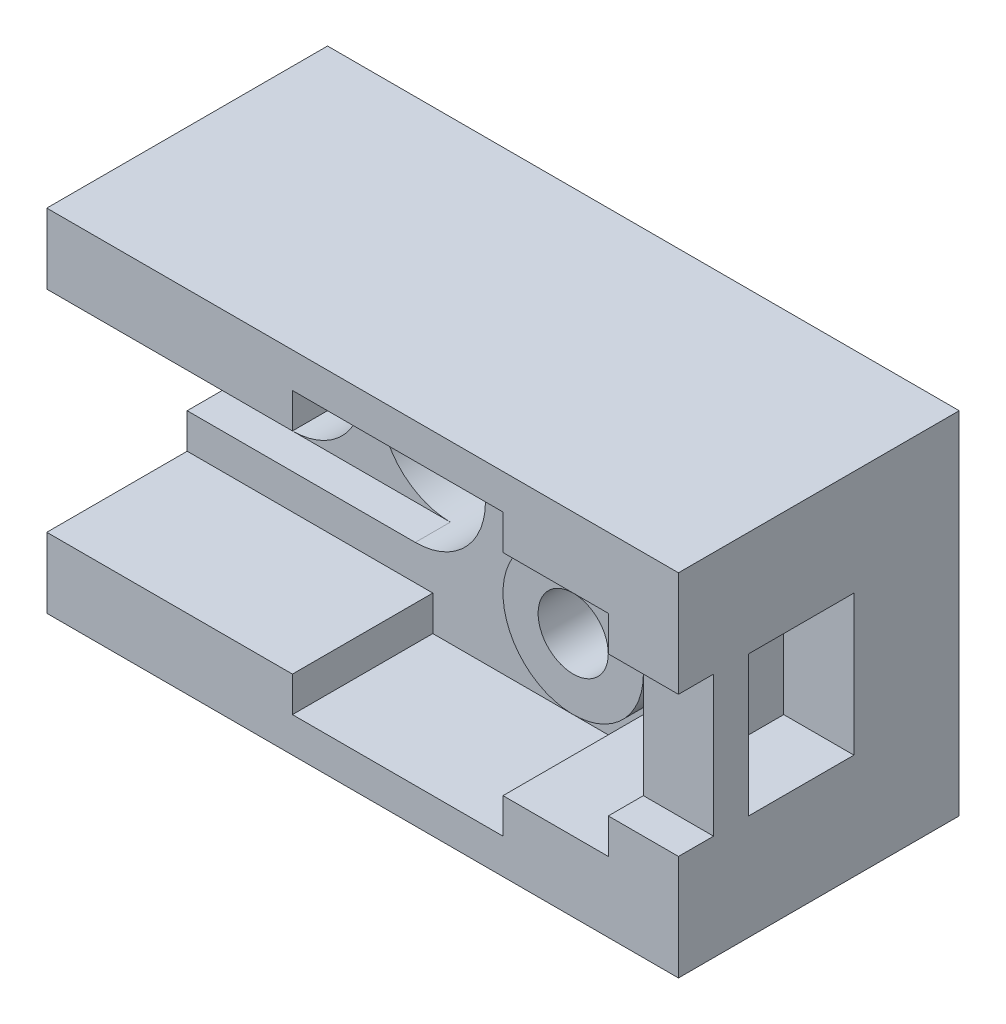
from build123d import *

# Parameters (mm, degrees)
SKETCH1_W           = 180
SKETCH1_H           = 100
BOSS_EXTRUDE1_DEPTH = 80
CUT_EXTRUDE1_DEPTH  = 80
SKETCH3_R           = 5
CUT_EXTRUDE2_DEPTH  = 20
SKETCH4_R           = 10
CUT_EXTRUDE3_DEPTH  = 60
SKETCH5_R           = 20
CUT_EXTRUDE4_DEPTH  = 60
SKETCH6_R           = 20
CUT_EXTRUDE5_DEPTH  = 50
CUT_EXTRUDE6_DEPTH  = 50
SKETCH8_W           = 10
SKETCH8_H           = 40
CUT_EXTRUDE7_DEPTH  = 207
CUT_EXTRUDE8_DEPTH  = 10
CUT_EXTRUDE9_DEPTH  = 10
SKETCH11_W          = 20
SKETCH11_H          = 40
CUT_EXTRUDE10_DEPTH = 30
SKETCH12_R          = 20
SKETCH12_R_2        = 10
BOSS_EXTRUDE3_DEPTH = 30
SKETCH13_R          = 20
CUT_EXTRUDE11_DEPTH = 30
SKETCH14_W          = 20
SKETCH14_H          = 40
CUT_EXTRUDE12_DEPTH = 10
SKETCH15_W          = 10
SKETCH15_H          = 40
BOSS_EXTRUDE5_DEPTH = 20


with BuildPart() as part:
    # Sketch1 → Boss-Extrude1 (new body)
    with BuildSketch(Plane.XY):
        with Locations((90, 50)):
            Rectangle(SKETCH1_W, SKETCH1_H)
    extrude(amount=BOSS_EXTRUDE1_DEPTH)

    # Sketch2 → Cut-Extrude1 (cut)
    with BuildSketch(Plane.XY.offset(80)):
        with BuildLine():
            Line((0, 70), (20, 70))
            ThreePointArc((20, 70), (40, 50), (20, 30))
            Line((20, 30), (0, 30))
            Line((0, 30), (0, 70))
        make_face()
    extrude(amount=-CUT_EXTRUDE1_DEPTH, mode=Mode.SUBTRACT)

    # Sketch3 → Cut-Extrude2 (cut)
    with BuildSketch(Plane(origin=(0, 0, 0), x_dir=(-1, 0, 0), z_dir=(0, 0, -1))):
        with Locations((-65, 50)):
            Circle(SKETCH3_R)
    extrude(amount=-CUT_EXTRUDE2_DEPTH, mode=Mode.SUBTRACT)

    # Sketch4 → Cut-Extrude3 (cut)
    with BuildSketch(Plane(origin=(0, 0, 0), x_dir=(-1, 0, 0), z_dir=(0, 0, -1))):
        with Locations((-130, 50)):
            Circle(SKETCH4_R)
    extrude(amount=-CUT_EXTRUDE3_DEPTH, mode=Mode.SUBTRACT)

    # Sketch5 → Cut-Extrude4 (cut)
    with BuildSketch(Plane.XY.offset(80)):
        with Locations((65, 50)):
            Circle(SKETCH5_R)
    extrude(amount=-CUT_EXTRUDE4_DEPTH, mode=Mode.SUBTRACT)

    # Sketch6 → Cut-Extrude5 (cut)
    with BuildSketch(Plane.XY.offset(80)):
        with Locations((130, 50)):
            Circle(SKETCH6_R)
    extrude(amount=-CUT_EXTRUDE5_DEPTH, mode=Mode.SUBTRACT)

    # Sketch7 → Cut-Extrude6 (cut)
    with BuildSketch(Plane.XY.offset(80)):
        with BuildLine():
            Line((20, 70), (65, 70))
            ThreePointArc((65, 70), (45, 50), (65, 30))
            Line((65, 30), (20, 30))
            ThreePointArc((20, 30), (40, 50), (20, 70))
        make_face()
    extrude(amount=-CUT_EXTRUDE6_DEPTH, mode=Mode.SUBTRACT)

    # Sketch8 → Cut-Extrude7 (cut)
    with BuildSketch(Plane(origin=(180, 0, 0), x_dir=(0, 0, -1), z_dir=(1, 0, 0))):
        with Locations((-75, 50)):
            Rectangle(SKETCH8_W, SKETCH8_H)
    extrude(amount=-CUT_EXTRUDE7_DEPTH, mode=Mode.SUBTRACT)

    # Sketch9 → Cut-Extrude8 (cut)
    with BuildSketch(Plane.XY.offset(80)):
        Polygon((0, 70), (160, 70), (160, 80), (130, 80), (130, 90), (70, 90), (70, 80), (0, 80), align=None)
    extrude(amount=-CUT_EXTRUDE8_DEPTH, mode=Mode.SUBTRACT)

    # Sketch10 → Cut-Extrude9 (cut)
    with BuildSketch(Plane.XY.offset(80)):
        Polygon((160, 20), (160, 30), (0, 30), (0, 20), (70, 20), (70, 10), (130, 10), (130, 20), align=None)
    extrude(amount=-CUT_EXTRUDE9_DEPTH, mode=Mode.SUBTRACT)

    # Sketch11 → Cut-Extrude10 (cut)
    with BuildSketch(Plane.XY.offset(70)):
        with Locations((170, 50)):
            Rectangle(SKETCH11_W, SKETCH11_H)
    extrude(amount=-CUT_EXTRUDE10_DEPTH, mode=Mode.SUBTRACT)

    # Sketch12 → Boss-Extrude3 (add)
    with BuildSketch(Plane.XY.offset(30)):
        with Locations((130, 50)):
            Circle(SKETCH12_R)
        with Locations(Location((130, 50, 0), (0, 0, 180))):
            Circle(SKETCH12_R_2, mode=Mode.SUBTRACT)
    extrude(amount=BOSS_EXTRUDE3_DEPTH)

    # Sketch13 → Cut-Extrude11 (cut)
    with BuildSketch(Plane.XY.offset(70)):
        with BuildLine():
            Line((130, 20), (160, 20))
            Line((160, 20), (160, 30))
            Line((160, 30), (160, 70))
            Line((160, 70), (160, 80))
            Line((160, 80), (130, 80))
            Line((130, 80), (130, 90))
            Line((130, 90), (70, 90))
            Line((70, 90), (70, 80))
            Line((70, 80), (0, 80))
            Line((0, 80), (0, 70))
            Line((0, 70), (65, 70))
            ThreePointArc((65, 70), (85, 50), (65, 30))
            Line((65, 30), (0, 30))
            Line((0, 30), (0, 20))
            Line((0, 20), (70, 20))
            Line((70, 20), (70, 10))
            Line((70, 10), (130, 10))
            Line((130, 10), (130, 20))
        make_face()
        with Locations((130, 50)):
            Circle(SKETCH13_R, mode=Mode.SUBTRACT)
    extrude(amount=-CUT_EXTRUDE11_DEPTH, mode=Mode.SUBTRACT)

    # Sketch14 → Cut-Extrude12 (cut)
    with BuildSketch(Plane.XY.offset(40)):
        with Locations((170, 50)):
            Rectangle(SKETCH14_W, SKETCH14_H)
    extrude(amount=-CUT_EXTRUDE12_DEPTH, mode=Mode.SUBTRACT)

    # Sketch15 → Boss-Extrude5 (add)
    with BuildSketch(Plane.ZY.offset(-160)):
        with Locations((65, 50)):
            Rectangle(SKETCH15_W, SKETCH15_H)
    extrude(amount=-BOSS_EXTRUDE5_DEPTH)


solid = part.part
